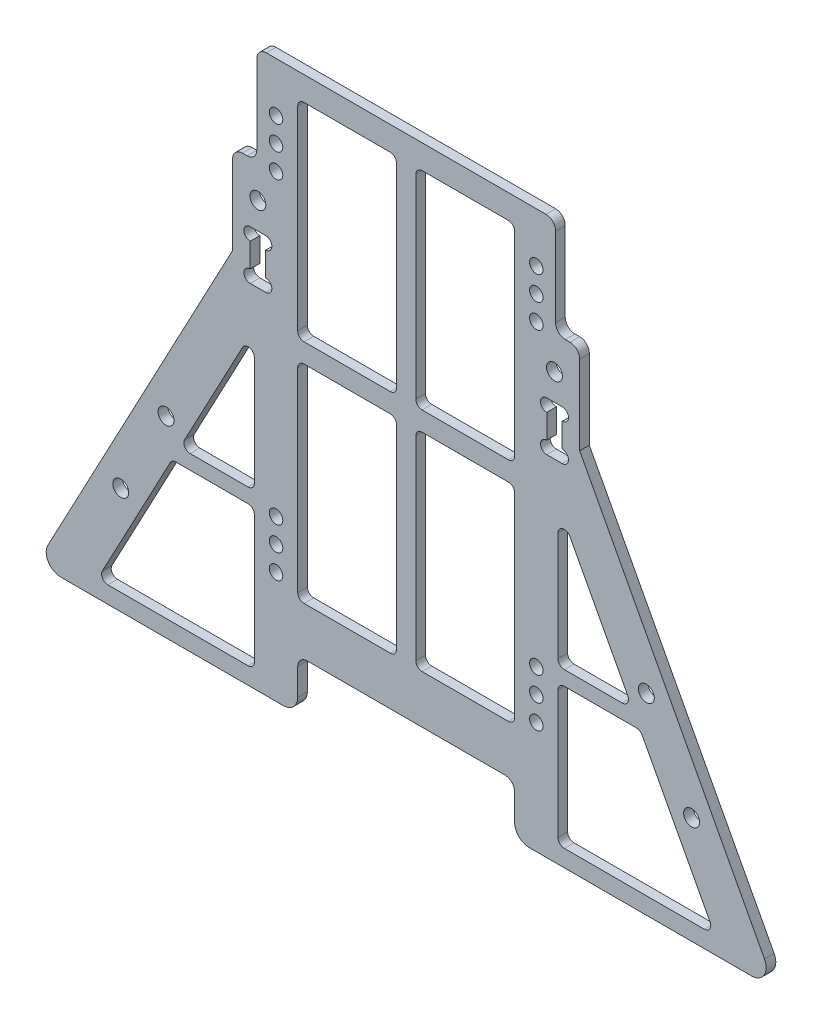
from build123d import *

# Parameters (mm, degrees)
SKETCH_1_W             = 72
SKETCH_1_H             = 150
EXTRUDE_1_DEPTH        = 1
SKETCH_2_R             = 1.4
CUT_EXTRUDE_1_DEPTH    = 2
PATTERN_LINEAR_1_COUNT = 2
PATTERN_LINEAR_1_PITCH = 5
PATTERN_LINEAR_2_COUNT = 2
PATTERN_LINEAR_2_PITCH = 5
SKETCH_9_W             = 72
SKETCH_9_H             = 7.5
CUT_EXTRUDE_4_DEPTH    = 5.5
EXTRUDE_5_DEPTH        = 2
SKETCH_12_W            = 72
SKETCH_12_H            = 48.96667592
CUT_EXTRUDE_5_DEPTH    = 10
SKETCH_14_R            = 1.65
CUT_EXTRUDE_6_DEPTH    = 10
SKETCH_15_W            = 3.2
SKETCH_15_H            = 10.2
CUT_EXTRUDE_7_DEPTH    = 10
SKETCH_16_R            = 1.3
CUT_EXTRUDE_8_DEPTH    = 10
SKETCH_17_R            = 1.65
CUT_EXTRUDE_9_DEPTH    = 10
FILLET_1_R             = 2
SKETCH_18_W            = 20.5
SKETCH_18_H            = 43
CUT_EXTRUDE_10_DEPTH   = 10
CUT_EXTRUDE_11_DEPTH   = 10
FILLET_2_R             = 1.3
SKETCH_20_W            = 45
SKETCH_20_H            = 26.033324079
CUT_EXTRUDE_12_DEPTH   = 10
FILLET_3_R             = 2
SKETCH_21_W            = 5
SKETCH_21_H            = 20.5
CUT_EXTRUDE_13_DEPTH   = 10
FILLET_4_R             = 2
SKETCH_22_W            = 156
SKETCH_22_H            = 2.5
CUT_EXTRUDE_14_DEPTH   = 3
FILLET_5_R             = 3


with BuildPart() as part:
    # 草图1 → 凸台-拉伸1 (new body, symmetric)
    with BuildSketch(Plane.XY):
        Rectangle(SKETCH_1_W, SKETCH_1_H)
    extrude(amount=EXTRUDE_1_DEPTH, both=True)

    # 草图2 → 切除-拉伸1 (cut)
    with BuildSketch(Plane(origin=(0, 0, -1), x_dir=(-1, 0, 0), z_dir=(0, 0, -1))):
        with Locations((-27, -12.3)):
            Circle(SKETCH_2_R)
        with Locations((27, -12.3)):
            Circle(SKETCH_2_R)
        with Locations((27, 59.7)):
            Circle(SKETCH_2_R)
        with Locations((-27, 59.7)):
            Circle(SKETCH_2_R)
    cut_extrude_1 = extrude(amount=-CUT_EXTRUDE_1_DEPTH, mode=Mode.SUBTRACT)

    # 阵列(线性)1: 切除-拉伸1 ×2
    with Locations(*[(0, -i * PATTERN_LINEAR_1_PITCH, 0) for i in range(1, PATTERN_LINEAR_1_COUNT)]):
        add(cut_extrude_1, mode=Mode.SUBTRACT)

    # 阵列(线性)2: 切除-拉伸1 ×2
    with Locations(*[(0, i * PATTERN_LINEAR_2_PITCH, 0) for i in range(1, PATTERN_LINEAR_2_COUNT)]):
        add(cut_extrude_1, mode=Mode.SUBTRACT)

    # 草图9 → 切除-拉伸4 (cut)
    with BuildSketch(Plane.XY.offset(1)):
        with Locations((0, -71.25)):
            Rectangle(SKETCH_9_W, SKETCH_9_H)
    extrude(amount=-CUT_EXTRUDE_4_DEPTH, mode=Mode.SUBTRACT)

    # 草图11 → 凸台-拉伸5 (add)
    with BuildSketch(Plane(origin=(0, 0, -1), x_dir=(-1, 0, 0), z_dir=(0, 0, -1))):
        Polygon((-36, 36), (-78, -43.01666204), (-36, -43.01666204), align=None)
        Polygon((36, -43.01666204), (36, 36), (78, -43.01666204), align=None)
    extrude(amount=-EXTRUDE_5_DEPTH)

    # 草图12 → 切除-拉伸5 (cut)
    with BuildSketch(Plane.XY.offset(1)):
        with Locations((0, -67.5)):
            Rectangle(SKETCH_12_W, SKETCH_12_H)
    extrude(amount=-CUT_EXTRUDE_5_DEPTH, mode=Mode.SUBTRACT)

    # 草图14 → 切除-拉伸6 (cut)
    with BuildSketch(Plane(origin=(0, 0, -1), x_dir=(-1, 0, 0), z_dir=(0, 0, -1))):
        with Locations((-49.82296811, -0.658849754)):
            Circle(SKETCH_14_R)
        with Locations((-59.209976564, -18.319089624)):
            Circle(SKETCH_14_R)
        with Locations((49.82296811, -0.658849754)):
            Circle(SKETCH_14_R)
        with Locations((59.209976564, -18.319089624)):
            Circle(SKETCH_14_R)
    extrude(amount=-CUT_EXTRUDE_6_DEPTH, mode=Mode.SUBTRACT)

    # 草图15 → 切除-拉伸7 (cut)
    with BuildSketch(Plane(origin=(0, 0, -1), x_dir=(-1, 0, 0), z_dir=(0, 0, -1))):
        with Locations((30.75, 37)):
            Rectangle(SKETCH_15_W, SKETCH_15_H)
        with Locations((-30.7673157, 37)):
            Rectangle(SKETCH_15_W, SKETCH_15_H)
    extrude(amount=-CUT_EXTRUDE_7_DEPTH, mode=Mode.SUBTRACT)

    # 草图16 → 切除-拉伸8 (cut)
    with BuildSketch(Plane(origin=(0, 0, -1), x_dir=(-1, 0, 0), z_dir=(0, 0, -1))):
        with Locations((-29.1673157, 40.8)):
            Circle(SKETCH_16_R)
        with Locations((-32.3673157, 40.8)):
            Circle(SKETCH_16_R)
        with Locations((-32.3673157, 33.2)):
            Circle(SKETCH_16_R)
        with Locations((-29.1673157, 33.2)):
            Circle(SKETCH_16_R)
        with Locations((29.1673157, 33.2)):
            Circle(SKETCH_16_R)
        with Locations((32.3673157, 33.2)):
            Circle(SKETCH_16_R)
        with Locations((32.3673157, 40.8)):
            Circle(SKETCH_16_R)
        with Locations((29.1673157, 40.8)):
            Circle(SKETCH_16_R)
    extrude(amount=-CUT_EXTRUDE_8_DEPTH, mode=Mode.SUBTRACT)

    # 草图17 → 切除-拉伸9 (cut)
    with BuildSketch(Plane(origin=(0, 0, -1), x_dir=(-1, 0, 0), z_dir=(0, 0, -1))):
        with Locations((-30.7673157, 47.6)):
            Circle(SKETCH_17_R)
        with Locations((30.7673157, 47.6)):
            Circle(SKETCH_17_R)
    extrude(amount=-CUT_EXTRUDE_9_DEPTH, mode=Mode.SUBTRACT)

    # 圆角1
    fillet_1_edges = [part.edges().sort_by_distance(p)[0] for p in [
        (-36, 75, 0),
        (36, 75, 0),
    ]]
    fillet(fillet_1_edges, radius=FILLET_1_R)

    # 草图18 → 切除-拉伸10 (cut)
    with BuildSketch(Plane(origin=(0, 0, -1), x_dir=(-1, 0, 0), z_dir=(0, 0, -1))):
        with Locations((12.25, 48.5)):
            Rectangle(SKETCH_18_W, SKETCH_18_H)
        with Locations((-12.25, 48.5)):
            Rectangle(SKETCH_18_W, SKETCH_18_H)
        with Locations((-12.25, 1.5)):
            Rectangle(SKETCH_18_W, SKETCH_18_H)
        with Locations((12.25, 1.5)):
            Rectangle(SKETCH_18_W, SKETCH_18_H)
    extrude(amount=-CUT_EXTRUDE_10_DEPTH, mode=Mode.SUBTRACT)

    # 草图19 → 切除-拉伸11 (cut)
    with BuildSketch(Plane(origin=(0, 0, -1), x_dir=(-1, 0, 0), z_dir=(0, 0, -1))):
        Polygon((-31.5, -7.895665687), (-48.573384423, -7.895665687), (-64.052168457, -37.01666204), (-31.5, -37.01666204), align=None)
        Polygon((-31.5, 24.225330666), (-46.978784034, -4.895665687), (-31.5, -4.895665687), align=None)
        Polygon((31.5, 24.225330666), (31.5, -4.895665687), (46.978784034, -4.895665687), align=None)
        Polygon((48.573384423, -7.895665687), (31.5, -7.895665687), (31.5, -37.01666204), (64.052168457, -37.01666204), align=None)
    extrude(amount=-CUT_EXTRUDE_11_DEPTH, mode=Mode.SUBTRACT)

    # 圆角2
    fillet_2_edges = [part.edges().sort_by_distance(p)[0] for p in [
        (-2, 23, 0),
        (-22.5, 23, 0),
        (-22.5, -20, 0),
        (-2, -20, 0),
        (2, 23, 0),
        (2, -20, 0),
        (22.5, -20, 0),
        (22.5, 23, 0),
        (2, 70, 0),
        (2, 27, 0),
        (22.5, 27, 0),
        (22.5, 70, 0),
        (-2, 70, 0),
        (-22.5, 70, 0),
        (-22.5, 27, 0),
        (-2, 27, 0),
        (-48.573384423, -7.895665687, 0),
        (-64.052168457, -37.01666204, 0),
        (-31.5, -37.01666204, 0),
        (-31.5, -7.895665687, 0),
        (-31.5, 24.225330666, 0),
        (-46.978784034, -4.895665687, 0),
        (-31.5, -4.895665687, 0),
        (31.5, -4.895665687, 0),
        (46.978784034, -4.895665687, 0),
        (31.5, 24.225330666, 0),
        (31.5, -7.895665687, 0),
        (31.5, -37.01666204, 0),
        (64.052168457, -37.01666204, 0),
        (48.573384423, -7.895665687, 0),
    ]]
    fillet(fillet_2_edges, radius=FILLET_2_R)

    # 草图20 → 切除-拉伸12 (cut)
    with BuildSketch(Plane(origin=(0, 0, -1), x_dir=(-1, 0, 0), z_dir=(0, 0, -1))):
        with Locations((0, -43.01666204)):
            Rectangle(SKETCH_20_W, SKETCH_20_H)
    extrude(amount=-CUT_EXTRUDE_12_DEPTH, mode=Mode.SUBTRACT)

    # 圆角3
    fillet_3_edges = [part.edges().sort_by_distance(p)[0] for p in [
        (22.5, -30, 0),
        (-22.5, -30, 0),
    ]]
    fillet(fillet_3_edges, radius=FILLET_3_R)

    # 草图21 → 切除-拉伸13 (cut)
    with BuildSketch(Plane(origin=(0, 0, -1), x_dir=(-1, 0, 0), z_dir=(0, 0, -1))):
        with Locations((-33.5, 64.75)):
            Rectangle(SKETCH_21_W, SKETCH_21_H)
        with Locations((33.5, 64.75)):
            Rectangle(SKETCH_21_W, SKETCH_21_H)
    extrude(amount=-CUT_EXTRUDE_13_DEPTH, mode=Mode.SUBTRACT)

    # 圆角4
    fillet_4_edges = [part.edges().sort_by_distance(p)[0] for p in [
        (31, 54.5, 0),
        (31, 75, 0),
        (36, 54.5, 0),
        (-36, 54.5, 0),
        (-31, 54.5, 0),
        (-31, 75, 0),
    ]]
    fillet(fillet_4_edges, radius=FILLET_4_R)

    # 草图22 → 切除-拉伸14 (cut, through all)
    with BuildSketch(Plane(origin=(0, 0, -1), x_dir=(-1, 0, 0), z_dir=(0, 0, -1))):
        with Locations((0, -41.76666204)):
            Rectangle(SKETCH_22_W, SKETCH_22_H)
    extrude(amount=-CUT_EXTRUDE_14_DEPTH, mode=Mode.SUBTRACT)

    # 圆角5
    fillet_5_edges = [part.edges().sort_by_distance(p)[0] for p in [
        (22.5, -40.51666204, 0),
        (76.671166343, -40.51666204, 0),
        (-76.671166343, -40.51666204, 0),
        (-22.5, -40.51666204, 0),
    ]]
    fillet(fillet_5_edges, radius=FILLET_5_R)


solid = part.part
